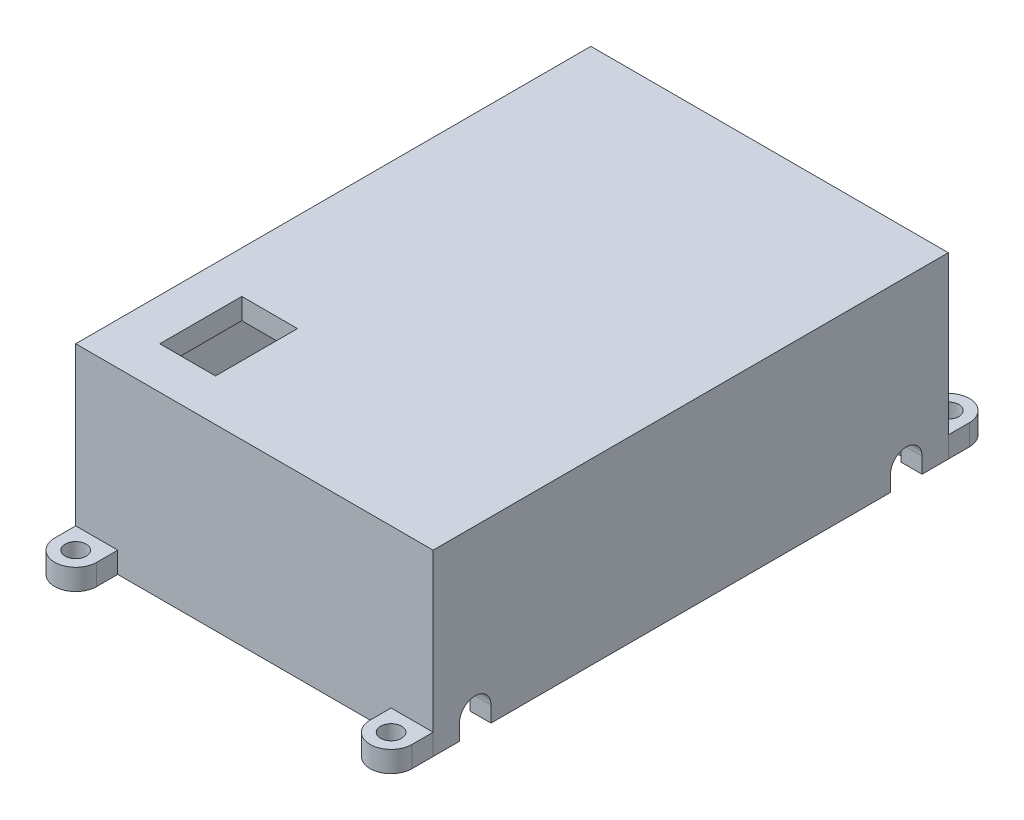
from build123d import *

# Parameters (mm, degrees)
SKETCH1_W           = 76.2
SKETCH1_H           = 114.3
BOSS_EXTRUDE1_DEPTH = 38.1
SHELL1_T            = 5.08
SKETCH2_R           = 5.08
SKETCH2_R_2         = 2.54
BOSS_EXTRUDE2_DEPTH = 5.08
CUT_EXTRUDE1_DEPTH  = 121.67673388
SKETCH4_W           = 13.462
SKETCH4_H           = 19.812
CUT_EXTRUDE2_DEPTH  = 95.706583193


with BuildPart() as part:
    # Sketch1 → Boss-Extrude1 (new body)
    with BuildSketch(Plane(origin=(0, 0, 0), x_dir=(1, 0, 0), z_dir=(0, 1, 0))):
        Rectangle(SKETCH1_W, SKETCH1_H)
    extrude(amount=BOSS_EXTRUDE1_DEPTH)

    # Shell1
    shell1_openings = [part.faces().sort_by_distance(p)[0] for p in [
        (0, 0, 0),
    ]]
    offset(amount=SHELL1_T, openings=shell1_openings, kind=Kind.INTERSECTION)

    # Sketch3 → Cut-Extrude1 (cut, through all)
    with BuildSketch(Plane(origin=(43.18, 0, 0), x_dir=(0, 0, -1), z_dir=(1, 0, 0))):
        with BuildLine():
            Line((-55.88, 3.81), (-55.88, 0))
            Line((-55.88, 0), (-48.26, 0))
            Line((-48.26, 0), (-48.26, 3.81))
            ThreePointArc((-48.26, 3.81), (-52.07, 7.62), (-55.88, 3.81))
        make_face()
        with BuildLine():
            Line((48.26, 3.81), (48.26, 0))
            Line((48.26, 0), (55.88, 0))
            Line((55.88, 0), (55.88, 3.81))
            ThreePointArc((55.88, 3.81), (52.07, 7.62), (48.26, 3.81))
        make_face()
    extrude(amount=-CUT_EXTRUDE1_DEPTH, mode=Mode.SUBTRACT)

    # Sketch4 → Cut-Extrude2 (cut, through all)
    with BuildSketch(Plane(origin=(0, 43.18, 0), x_dir=(1, 0, 0), z_dir=(0, 1, 0))):
        with Locations((-26.289, -42.164)):
            Rectangle(SKETCH4_W, SKETCH4_H)
    extrude(amount=-CUT_EXTRUDE2_DEPTH, mode=Mode.SUBTRACT)


with BuildPart() as body_2:
    # Sketch2 → Boss-Extrude2 (new body)
    with BuildSketch(Plane.XZ):
        with Locations((-38.1, 67.31)):
            Circle(SKETCH2_R)
        with Locations(Location((-38.1, 67.31, 0), (0, 0, 270))):
            Circle(SKETCH2_R_2, mode=Mode.SUBTRACT)
        with BuildLine():
            Line((-33.02, 62.23), (-33.02, 67.31))
            ThreePointArc((-33.02, 67.31), (-34.507897552, 63.717897552), (-38.1, 62.23))
            Line((-38.1, 62.23), (-33.02, 62.23))
        make_face()
        with BuildLine():
            ThreePointArc((-38.1, 62.23), (-41.692102448, 63.717897552), (-43.18, 67.31))
            Line((-43.18, 67.31), (-43.18, 62.23))
            Line((-43.18, 62.23), (-38.1, 62.23))
        make_face()
        with Locations((38.1, 67.31)):
            Circle(SKETCH2_R)
        with Locations(Location((38.1, 67.31, 0), (0, 0, 270))):
            Circle(SKETCH2_R_2, mode=Mode.SUBTRACT)
        with BuildLine():
            Line((33.02, 67.31), (33.02, 62.23))
            Line((33.02, 62.23), (38.1, 62.23))
            ThreePointArc((38.1, 62.23), (34.507897552, 63.717897552), (33.02, 67.31))
        make_face()
        with BuildLine():
            ThreePointArc((43.18, 67.31), (41.692102448, 63.717897552), (38.1, 62.23))
            Line((38.1, 62.23), (43.18, 62.23))
            Line((43.18, 62.23), (43.18, 67.31))
        make_face()
        with Locations((38.1, -67.31)):
            Circle(SKETCH2_R)
        with Locations(Location((38.1, -67.31, 0), (0, 0, 270))):
            Circle(SKETCH2_R_2, mode=Mode.SUBTRACT)
        with BuildLine():
            Line((33.02, -62.23), (33.02, -67.31))
            ThreePointArc((33.02, -67.31), (34.507897552, -63.717897552), (38.1, -62.23))
            Line((38.1, -62.23), (33.02, -62.23))
        make_face()
        with BuildLine():
            ThreePointArc((38.1, -62.23), (41.692102448, -63.717897552), (43.18, -67.31))
            Line((43.18, -67.31), (43.18, -62.23))
            Line((43.18, -62.23), (38.1, -62.23))
        make_face()
        with Locations((-38.1, -67.31)):
            Circle(SKETCH2_R)
        with Locations(Location((-38.1, -67.31, 0), (0, 0, 270))):
            Circle(SKETCH2_R_2, mode=Mode.SUBTRACT)
        with BuildLine():
            Line((-33.02, -67.31), (-33.02, -62.23))
            Line((-33.02, -62.23), (-38.1, -62.23))
            ThreePointArc((-38.1, -62.23), (-34.507897552, -63.717897552), (-33.02, -67.31))
        make_face()
        with BuildLine():
            ThreePointArc((-43.18, -67.31), (-41.692102448, -63.717897552), (-38.1, -62.23))
            Line((-38.1, -62.23), (-43.18, -62.23))
            Line((-43.18, -62.23), (-43.18, -67.31))
        make_face()
    extrude(amount=-BOSS_EXTRUDE2_DEPTH)


solid = Compound([part.part, body_2.part])
